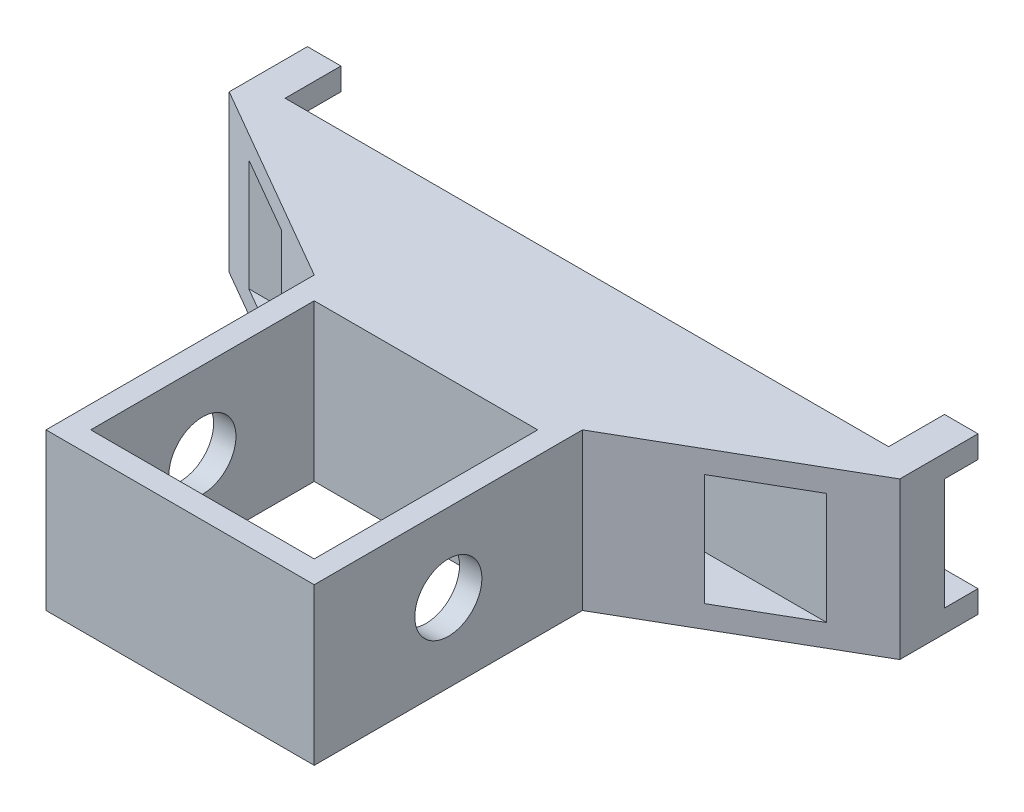
from build123d import *

# Parameters (mm, degrees)
SKETCH_1_W          = 12
SKETCH_1_H          = 12
EXTRUDE_1_DEPTH     = 7
SKETCH_2_W          = 10
SKETCH_2_H          = 10
CUT_EXTRUDE_1_DEPTH = 8
SKETCH_4_R          = 1.5
CUT_EXTRUDE_2_DEPTH = 22
SKETCH_5_W          = 27
SKETCH_5_H          = 2.5
CUT_EXTRUDE_3_DEPTH = 8
SKETCH_6_W          = 2
SKETCH_6_H          = 5
CUT_EXTRUDE_4_DEPTH = 31
SKETCH_7_W          = 1.5
SKETCH_7_H          = 5
CUT_EXTRUDE_5_DEPTH = 31


with BuildPart() as part:
    # Эскиз1 → Бобышка-Вытянуть1 (new body)
    with BuildSketch(Plane(origin=(0, 0, 0), x_dir=(1, 0, 0), z_dir=(0, 1, 0))):
        with Locations((0, 6)):
            Rectangle(SKETCH_1_W, SKETCH_1_H)
        Polygon((-15, 17.196152423), (-6, 12), (6, 12), (15, 17.196152423), (15, 20.696152423), (-15, 20.696152423), align=None)
    extrude(amount=EXTRUDE_1_DEPTH)

    # Эскиз2 → Вырез-Вытянуть1 (cut, through all)
    with BuildSketch(Plane(origin=(0, 7, 0), x_dir=(1, 0, 0), z_dir=(0, 1, 0))):
        with Locations((0, 6)):
            Rectangle(SKETCH_2_W, SKETCH_2_H)
    extrude(amount=-CUT_EXTRUDE_1_DEPTH, mode=Mode.SUBTRACT)

    # Эскиз4 → Вырез-Вытянуть2 (cut, through all)
    with BuildSketch(Plane.ZY.offset(6)):
        with Locations((-6, 3.5)):
            Circle(SKETCH_4_R)
    extrude(amount=-CUT_EXTRUDE_2_DEPTH, mode=Mode.SUBTRACT)

    # Эскиз5 → Вырез-Вытянуть3 (cut, through all)
    with BuildSketch(Plane.XZ):
        with Locations((0, -19.446152423)):
            Rectangle(SKETCH_5_W, SKETCH_5_H)
    extrude(amount=-CUT_EXTRUDE_3_DEPTH, mode=Mode.SUBTRACT)

    # Эскиз6 → Вырез-Вытянуть4 (cut, through all)
    with BuildSketch(Plane(origin=(15, 0, 0), x_dir=(0, 0, -1), z_dir=(1, 0, 0))):
        with Locations((15, 3.5)):
            Rectangle(SKETCH_6_W, SKETCH_6_H)
    extrude(amount=-CUT_EXTRUDE_4_DEPTH, mode=Mode.SUBTRACT)

    # Эскиз7 → Вырез-Вытянуть5 (cut, through all)
    with BuildSketch(Plane.ZY.offset(15)):
        with Locations((-19.946152423, 3.5)):
            Rectangle(SKETCH_7_W, SKETCH_7_H)
    extrude(amount=-CUT_EXTRUDE_5_DEPTH, mode=Mode.SUBTRACT)


solid = part.part
